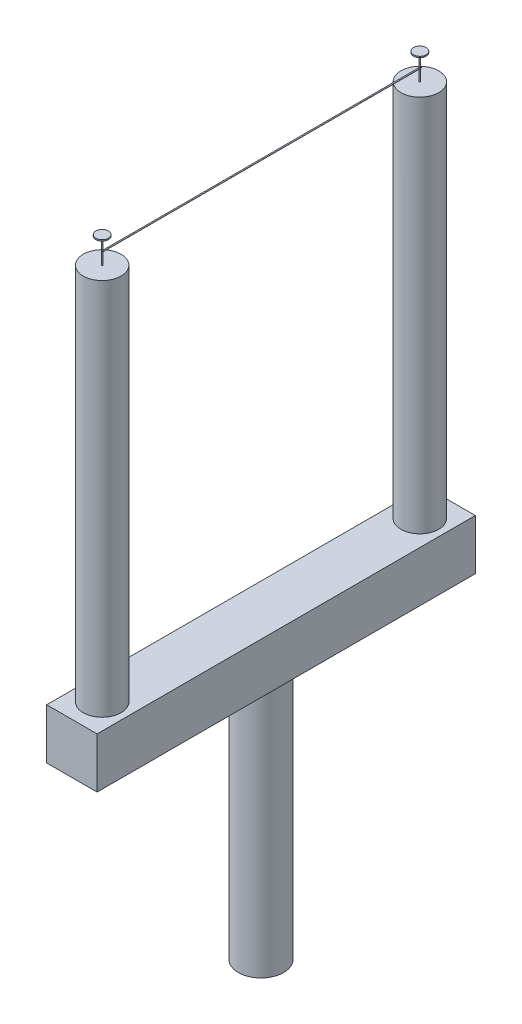
from build123d import *

# Parameters (mm, degrees)
SKETCH1_W           = 20
SKETCH1_H           = 20
BOSS_EXTRUDE1_DEPTH = 150
SKETCH3_R           = 9
BOSS_EXTRUDE2_DEPTH = 100
SKETCH2_R           = 7.5
BOSS_EXTRUDE3_DEPTH = 150
SKETCH7_R           = 0.25
BOSS_EXTRUDE4_DEPTH = 10
SKETCH8_R           = 2.5
BOSS_EXTRUDE5_DEPTH = 0.5
SKETCH19_W          = 126.5
SKETCH19_H          = 0.1
BOSS_EXTRUDE6_DEPTH = 0.5


with BuildPart() as part:
    # Sketch1 → Boss-Extrude1 (new body)
    with BuildSketch(Plane.XY):
        Rectangle(SKETCH1_W, SKETCH1_H)
    extrude(amount=BOSS_EXTRUDE1_DEPTH)

    # Sketch3 → Boss-Extrude2 (add)
    with BuildSketch(Plane.XZ.offset(10)):
        with Locations((0, 75)):
            Circle(SKETCH3_R)
    extrude(amount=BOSS_EXTRUDE2_DEPTH)

    # Sketch2 → Boss-Extrude3 (add)
    with BuildSketch(Plane(origin=(0, 10, 0), x_dir=(1, 0, 0), z_dir=(0, 1, 0))):
        with Locations((0, -12)):
            Circle(SKETCH2_R)
        with Locations((0, -138)):
            Circle(SKETCH2_R)
    extrude(amount=BOSS_EXTRUDE3_DEPTH)

    # Sketch7 → Boss-Extrude4 (add)
    with BuildSketch(Plane(origin=(0, 160, 0), x_dir=(1, 0, 0), z_dir=(0, 1, 0))):
        with Locations((0, -12)):
            Circle(SKETCH7_R)
        with Locations((0, -138)):
            Circle(SKETCH7_R)
    extrude(amount=BOSS_EXTRUDE4_DEPTH)

    # Sketch8 → Boss-Extrude5 (add)
    with BuildSketch(Plane(origin=(0, 170, 0), x_dir=(1, 0, 0), z_dir=(0, 1, 0))):
        with Locations((0, -12)):
            Circle(SKETCH8_R)
        with Locations((0, -138)):
            Circle(SKETCH8_R)
    extrude(amount=BOSS_EXTRUDE5_DEPTH)

    # Sketch19 → Boss-Extrude6 (add)
    with BuildSketch(Plane(origin=(0, 0, 0), x_dir=(0, 0, -1), z_dir=(1, 0, 0))):
        with Locations((-75, 164.95)):
            Rectangle(SKETCH19_W, SKETCH19_H)
    extrude(amount=BOSS_EXTRUDE6_DEPTH)


solid = part.part
